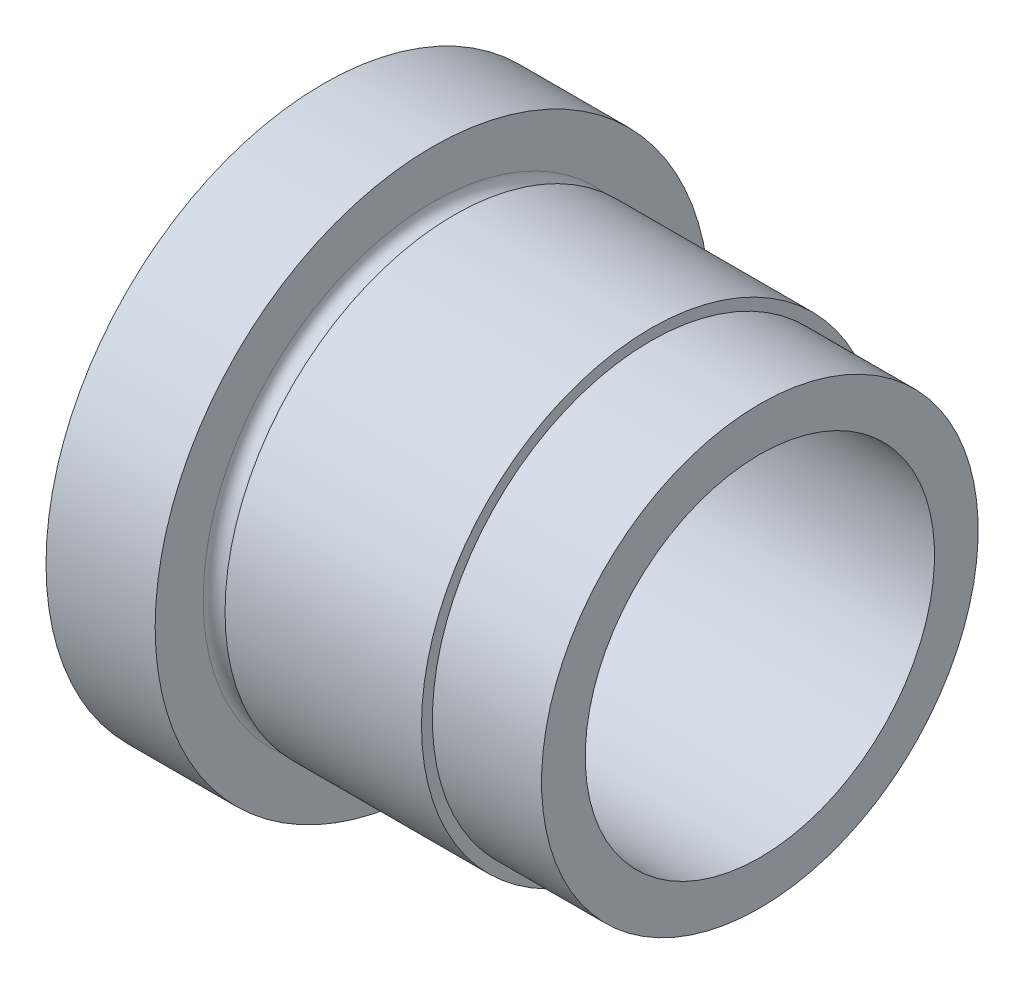
from build123d import *


with BuildPart() as part:
    # Esboço1 → Revolução1 (revolve)
    with BuildSketch(Plane.XY, mode=Mode.PRIVATE) as revolu_o1_sk:
        with BuildLine():
            Line((0, 8.05), (0, 12.7))
            Line((0, 12.7), (5, 12.7))
            Line((5, 12.7), (5, 10.5))
            ThreePointArc((5, 10.5), (5.5, 10), (6, 10.5))
            Line((6, 10.5), (15, 10.5))
            Line((15, 10.5), (15, 10))
            Line((15, 10), (20, 10))
            Line((20, 10), (20, 8))
            Line((20, 8), (0.1, 8))
            Line((0.1, 8), (0.1, 8.05))
            Line((0.1, 8.05), (0, 8.05))
        make_face()
    revolve(revolu_o1_sk.sketch.rotate(Axis((-138.925343643, 0, 0), (1, 0, 0)), 180), axis=Axis((-138.925343643, 0, 0), (1, 0, 0)))  # turned: the seam where the file's is


solid = part.part
